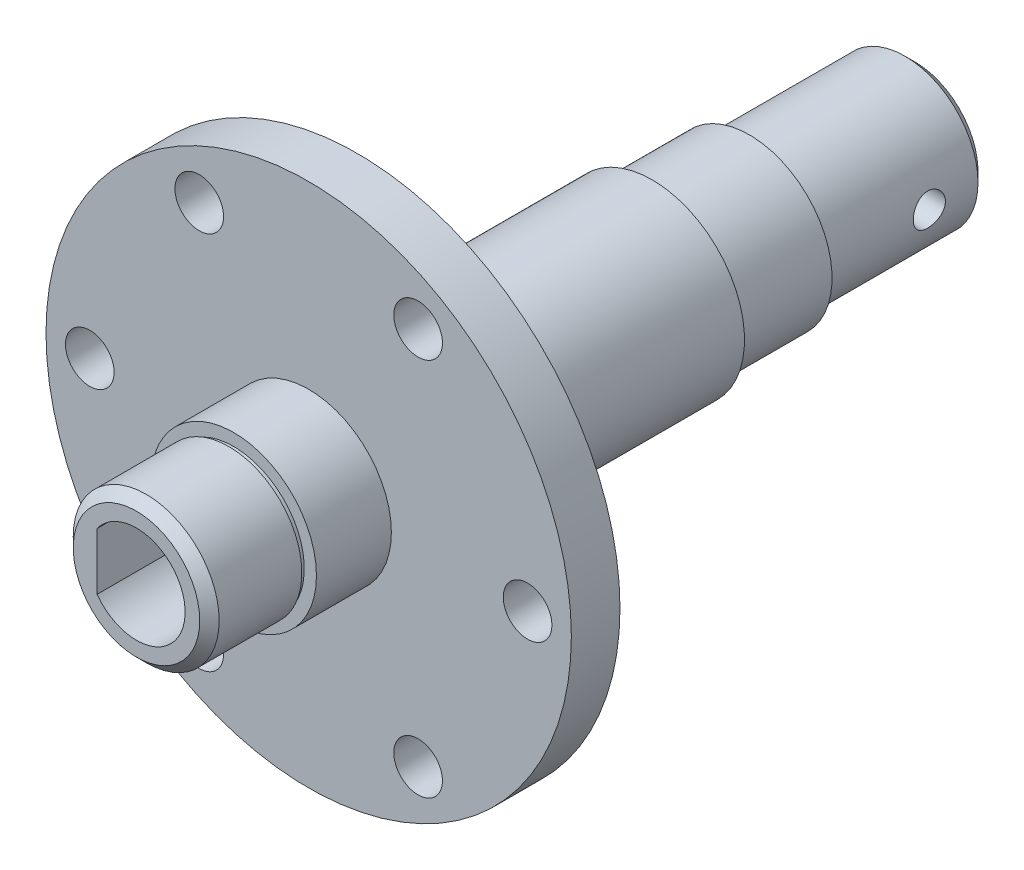
from build123d import *

# Parameters (mm, degrees)
SKETCH_1_R                = 7
EXTRUDE_1_DEPTH           = 54
SKETCH_2_R                = 5
EXTRUDE_2_DEPTH           = 7
CHAMFER_1_SIZE            = 1
SKETCH_3_R                = 10
EXTRUDE_3_DEPTH           = 2
SKETCH_4_R                = 6
EXTRUDE_4_DEPTH           = 25
SKETCH_7_R                = 10
EXTRUDE_5_DEPTH           = 4.3
SKETCH_9_R                = 10
SKETCH_9_R_2              = 6
CUT_EXTRUDE_3_DEPTH       = 1.3
SKETCH_11_R               = 27
SKETCH_11_R_2             = 10
EXTRUDE_6_DEPTH           = 5
SKETCH_12_R               = 9.5
SKETCH_12_R_2             = 6
EXTRUDE_7_DEPTH           = 30
SKETCH_14_R               = 2.5
CUT_EXTRUDE_4_DEPTH       = 10
CUT_EXTRUDE_5_DEPTH       = 30
CHAMFER_2_SIZE            = 1
HOLE_WIZARD_M3_1_D        = 2.5
HOLE_WIZARD_M3_1_DEPTH    = 18.5
HOLE_WIZARD_M3_1_TIP      = 0.751075774
SKETCH_22_W               = 38.47112098
SKETCH_22_H               = 24.703275639
CUT_EXTRUDE_10_DEPTH      = 28
CUT_EXTRUDE_10_DEPTH_BACK = 28
SKETCH_24_R               = 9.5
EXTRUDE_9_DEPTH           = 10.3
SKETCH_25_R               = 7.5
EXTRUDE_10_DEPTH          = 17
SKETCH_26_W               = 19.870375241
SKETCH_26_H               = 17.333591793
CUT_EXTRUDE_11_DEPTH      = 28
CUT_EXTRUDE_11_DEPTH_BACK = 28
SKETCH_27_R               = 9.5
EXTRUDE_11_DEPTH          = 7.7
SKETCH_29_R               = 7.5
EXTRUDE_12_DEPTH          = 10
CUT_EXTRUDE_12_REACH      = 82
HOLE_WIZARD_M4_1_D        = 3.3
CHAMFER_4_SIZE            = 1
SKETCH_33_R               = 9.5
SKETCH_33_R_2             = 8.5
CUT_EXTRUDE_13_DEPTH      = 10
SKETCH_34_R               = 9.5
SKETCH_34_R_2             = 8.5
CUT_EXTRUDE_14_DEPTH      = 7.7
SKETCH_35_W               = 0.25
SKETCH_35_H               = 0.5
SKETCH_36_W               = 0.25
SKETCH_36_H               = 0.5


with BuildPart() as part:
    # 草图1 → 凸台-拉伸1 (new body)
    with BuildSketch(Plane.XY):
        Circle(SKETCH_1_R)
    extrude(amount=EXTRUDE_1_DEPTH)

    # 草图2 → 凸台-拉伸2 (add)
    with BuildSketch(Plane.XY.offset(54)):
        Circle(SKETCH_2_R)
    extrude(amount=EXTRUDE_2_DEPTH)

    # 倒角1
    chamfer_1_edges = [part.edges().sort_by_distance(p)[0] for p in [
        (-5, 0, 61),
    ]]
    chamfer(chamfer_1_edges, length=CHAMFER_1_SIZE)

    # 草图3 → 凸台-拉伸3 (add)
    with BuildSketch(Plane.XY.offset(42)):
        Circle(SKETCH_3_R)
    extrude(amount=-EXTRUDE_3_DEPTH)

    # 草图4 → 凸台-拉伸4 (add)
    with BuildSketch(Plane(origin=(0, 0, 0), x_dir=(-1, 0, 0), z_dir=(0, 0, -1))):
        Circle(SKETCH_4_R)
    extrude(amount=EXTRUDE_4_DEPTH)

    # 草图7 → 凸台-拉伸5 (add)
    with BuildSketch(Plane.XY.offset(42)):
        Circle(SKETCH_7_R)
    extrude(amount=EXTRUDE_5_DEPTH)

    # 草图9 → 切除-拉伸3 (cut)
    with BuildSketch(Plane(origin=(0, 0, 40), x_dir=(-1, 0, 0), z_dir=(0, 0, -1))):
        Circle(SKETCH_9_R)
        Circle(SKETCH_9_R_2, mode=Mode.SUBTRACT)
    extrude(amount=-CUT_EXTRUDE_3_DEPTH, mode=Mode.SUBTRACT)

    # 草图11 → 凸台-拉伸6 (add)
    with BuildSketch(Plane.XY.offset(46.3)):
        Circle(SKETCH_11_R)
        Circle(SKETCH_11_R_2, mode=Mode.SUBTRACT)
    extrude(amount=-EXTRUDE_6_DEPTH)

    # 草图12 → 凸台-拉伸7 (add)
    with BuildSketch(Plane(origin=(0, 0, 41.3), x_dir=(-1, 0, 0), z_dir=(0, 0, -1))):
        Circle(SKETCH_12_R)
        Circle(SKETCH_12_R_2, mode=Mode.SUBTRACT)
    extrude(amount=EXTRUDE_7_DEPTH)

    # 草图14 → 切除-拉伸4 (cut)
    with BuildSketch(Plane.XY.offset(46.3)):
        with Locations((22.5, 0)):
            Circle(SKETCH_14_R)
        with Locations((11.25, -19.485571585)):
            Circle(SKETCH_14_R)
        with Locations((-11.25, -19.485571585)):
            Circle(SKETCH_14_R)
        with Locations((-22.5, 0)):
            Circle(SKETCH_14_R)
        with Locations((-11.25, 19.485571585)):
            Circle(SKETCH_14_R)
        with Locations((11.25, 19.485571585)):
            Circle(SKETCH_14_R)
    extrude(amount=-CUT_EXTRUDE_4_DEPTH, mode=Mode.SUBTRACT)

    # 草图13 → 切除-拉伸5 (cut)
    with BuildSketch(Plane(origin=(0, 0, -25), x_dir=(-1, 0, 0), z_dir=(0, 0, -1))):
        with BuildLine():
            Line((2.15, 2.092247595), (2.15, -2.092247595))
            ThreePointArc((2.15, -2.092247595), (0, -3), (-2.15, -2.092247595))
            Line((-2.15, -2.092247595), (-2.15, 2.092247595))
            ThreePointArc((-2.15, 2.092247595), (0, 3), (2.15, 2.092247595))
        make_face()
    extrude(amount=-CUT_EXTRUDE_5_DEPTH, mode=Mode.SUBTRACT)

    # 倒角2
    chamfer_2_edges = [part.edges().sort_by_distance(p)[0] for p in [
        (6, 0, -25),
    ]]
    chamfer(chamfer_2_edges, length=CHAMFER_2_SIZE)

    # M3 螺纹孔1
    with Locations(Plane(origin=(7.85, 0, -17), x_dir=(0, 0, 1), z_dir=(1, 0, 0))):
        with Locations((0, 0)):
            Hole(HOLE_WIZARD_M3_1_D / 2, depth=HOLE_WIZARD_M3_1_DEPTH)
            with Locations((0, 0, -(HOLE_WIZARD_M3_1_DEPTH + HOLE_WIZARD_M3_1_TIP / 2))):  # 118° drill point
                Cone(0, HOLE_WIZARD_M3_1_D / 2, HOLE_WIZARD_M3_1_TIP, mode=Mode.SUBTRACT)

    # 草图22 → 切除-拉伸10 (cut, two sides)
    with BuildSketch(Plane(origin=(0, 0, 0), x_dir=(0, 0, -1), z_dir=(1, 0, 0))) as cut_extrude_10_sk:
        with Locations((7.93556049, 2.744045787)):
            Rectangle(SKETCH_22_W, SKETCH_22_H)
    extrude(amount=CUT_EXTRUDE_10_DEPTH, mode=Mode.SUBTRACT)
    extrude(cut_extrude_10_sk.sketch, amount=-CUT_EXTRUDE_10_DEPTH_BACK, mode=Mode.SUBTRACT)

    # 草图24 → 凸台-拉伸9 (add)
    with BuildSketch(Plane(origin=(0, 0, 11.3), x_dir=(-1, 0, 0), z_dir=(0, 0, -1))):
        Circle(SKETCH_24_R)
    extrude(amount=EXTRUDE_9_DEPTH)

    # 草图25 → 凸台-拉伸10 (add)
    with BuildSketch(Plane(origin=(0, 0, 1), x_dir=(-1, 0, 0), z_dir=(0, 0, -1))):
        Circle(SKETCH_25_R)
    extrude(amount=EXTRUDE_10_DEPTH)

    # 草图26 → 切除-拉伸11 (cut, two sides)
    with BuildSketch(Plane(origin=(0, 0, 0), x_dir=(0, 0, -1), z_dir=(1, 0, 0))) as cut_extrude_11_sk:
        with Locations((-56.23518762, 1.256529054)):
            Rectangle(SKETCH_26_W, SKETCH_26_H)
    extrude(amount=CUT_EXTRUDE_11_DEPTH, mode=Mode.SUBTRACT)
    extrude(cut_extrude_11_sk.sketch, amount=-CUT_EXTRUDE_11_DEPTH_BACK, mode=Mode.SUBTRACT)

    # 草图27 → 凸台-拉伸11 (add)
    with BuildSketch(Plane.XY.offset(46.3)):
        Circle(SKETCH_27_R)
    extrude(amount=EXTRUDE_11_DEPTH)

    # 草图29 → 凸台-拉伸12 (add)
    with BuildSketch(Plane.XY.offset(54)):
        Circle(SKETCH_29_R)
    extrude(amount=EXTRUDE_12_DEPTH)

    # 草图30 → 切除-拉伸12 (cut, up to next)
    with BuildSketch(Plane(origin=(0, 0, -16), x_dir=(-1, 0, 0), z_dir=(0, 0, -1)), mode=Mode.PRIVATE) as cut_extrude_12_sk1:
        with BuildLine():
            Line((4.05, 2.932149382), (4.05, -2.932149382))
            ThreePointArc((4.05, -2.932149382), (-5, 0), (4.05, 2.932149382))
        make_face()
    cut_extrude_12_tool1 = extrude(cut_extrude_12_sk1.sketch, amount=-CUT_EXTRUDE_12_REACH, mode=Mode.PRIVATE) & part.part
    add(cut_extrude_12_tool1.solids().sort_by_distance((0.224834, 0, -16))[0], mode=Mode.SUBTRACT)

    # M4 螺纹孔1 (through all)
    with Locations(Plane.ZY.offset(9.5)):
        with Locations((-10, 0)):
            Hole(HOLE_WIZARD_M4_1_D / 2)

    # 倒角4
    chamfer_4_edges = [part.edges().sort_by_distance(p)[0] for p in [
        (7.5, 0, -16),
        (-7.5, 0, 64),
    ]]
    chamfer(chamfer_4_edges, length=CHAMFER_4_SIZE)

    # 草图33 → 切除-拉伸13 (cut)
    with BuildSketch(Plane(origin=(0, 0, 1), x_dir=(-1, 0, 0), z_dir=(0, 0, -1))):
        Circle(SKETCH_33_R)
        Circle(SKETCH_33_R_2, mode=Mode.SUBTRACT)
    extrude(amount=-CUT_EXTRUDE_13_DEPTH, mode=Mode.SUBTRACT)

    # 草图34 → 切除-拉伸14 (cut)
    with BuildSketch(Plane.XY.offset(54)):
        Circle(SKETCH_34_R)
        Circle(SKETCH_34_R_2, mode=Mode.SUBTRACT)
    extrude(amount=-CUT_EXTRUDE_14_DEPTH, mode=Mode.SUBTRACT)

    # 草图35 → 切除-旋转1 (revolve, cut)
    with BuildSketch(Plane(origin=(0, 0, 0), x_dir=(1, 0, 0), z_dir=(0, 1, 0))):
        with Locations((7.375, -0.75)):
            Rectangle(SKETCH_35_W, SKETCH_35_H)
    revolve(axis=Axis((0, 0, 1), (0, 0, -1)), mode=Mode.SUBTRACT)

    # 草图36 → 切除-旋转2 (revolve, cut)
    with BuildSketch(Plane(origin=(0, 0, 0), x_dir=(1, 0, 0), z_dir=(0, 1, 0))):
        with Locations((7.375, -54.25)):
            Rectangle(SKETCH_36_W, SKETCH_36_H)
    revolve(axis=Axis((0, 0, 54), (0, 0, 1)), mode=Mode.SUBTRACT)


solid = part.part
